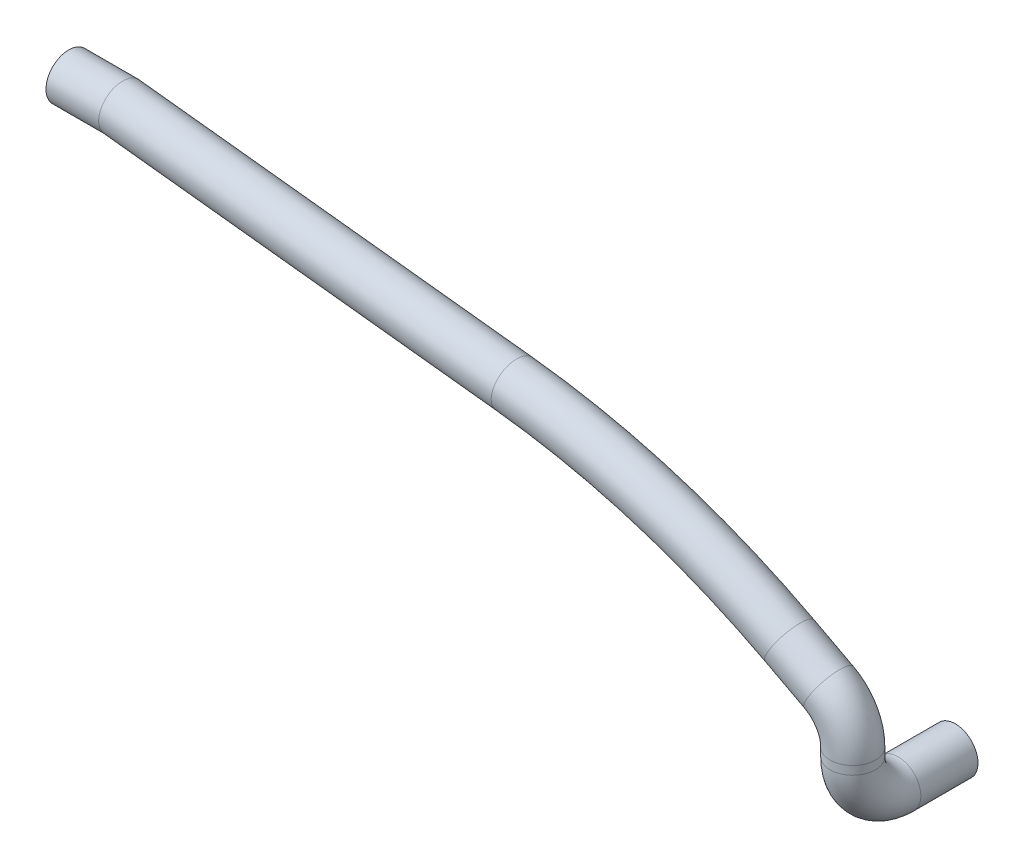
from build123d import *

# Parameters (mm, degrees)
WYCI_GNI_CIE_PO_CIE_CE_CIENKA_CIAN_2_R   = 10
WYCI_GNI_CIE_PO_CIE_CE_CIENKA_CIAN_2_R_2 = 7.5


with BuildPart() as part:
    # Wyci_gni_cie po _cie_ce-Cienka _cianka1: sweep along a curve in space
    with BuildLine() as wyci_gni_cie_po_cie_ce_cienka_cianka1_path:
        Line((344.842449098, -107.760635274, -45.933666989), (344.842449098, -107.760635274, -30.175831262))
        Line((344.842449098, -107.760635274, -30.175831262), (344.842449098, -107.760635274, -20.751368547))
        ThreePointArc((344.842449098, -107.760635274, -20.751368547), (344.842449098, -101.902770898, -6.609232923), (344.842449098, -87.760635274, -0.751368547))
        Line((344.842449098, -87.760635274, -0.751368547), (344.842449098, -84.035691476, -0.751368547))
        ThreePointArc((334.225321639, -66.373238459, -0.72656527), (341.983881451, -73.731732804, -0.744690484), (344.842449098, -84.035691476, -0.751368547))
        Line((334.225321639, -66.373238459, -0.72656527), (316.94225441, -57.191911349, -0.686189311))
        ThreePointArc((316.94225441, -57.191911349, -0.686189311), (258.162073815, -32.716996153, -0.548869578), (195.849321408, -19.630756919, -0.403297204))
        Line((195.849321408, -19.630756919, -0.403297204), (23.216575519, 0, 0))
        Line((23.216575519, 0, 0), (0, 0, 0))
    # Wyci_gni_cie po _cie_ce-Cienka _cian 2 (on start of the path) → Wyci_gni_cie po _cie_ce-Cienka _cianka1 (sweep)
    with BuildSketch(Plane(origin=(344.842449098, -107.760635274, -45.933666989), x_dir=(0, 1, 0), z_dir=(0, 0, 1))):
        Circle(WYCI_GNI_CIE_PO_CIE_CE_CIENKA_CIAN_2_R)
        Circle(WYCI_GNI_CIE_PO_CIE_CE_CIENKA_CIAN_2_R_2, mode=Mode.SUBTRACT)
    sweep(path=wyci_gni_cie_po_cie_ce_cienka_cianka1_path.line, transition=Transition.RIGHT)


solid = part.part
